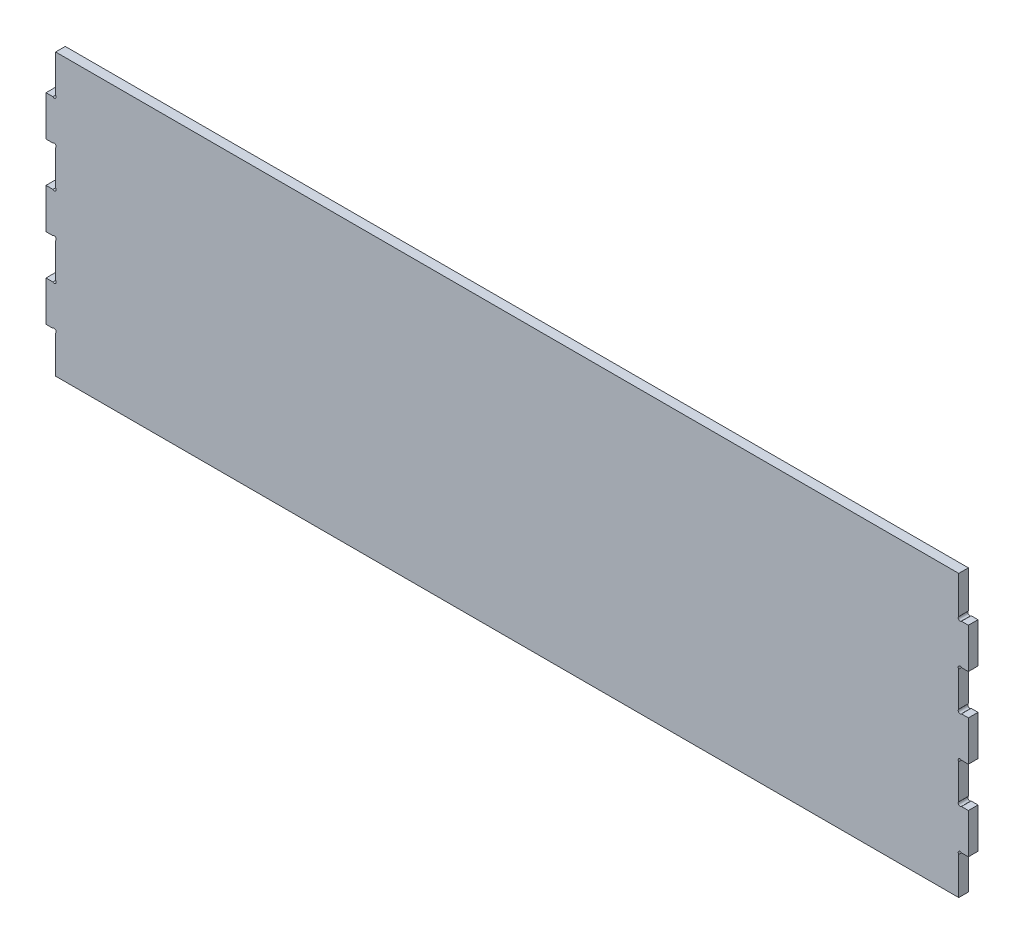
from build123d import *

# Parameters (mm, degrees)
BOSS_EXTRUDE1_DEPTH = 12


with BuildPart() as part:
    # Sketch1 → Boss-Extrude1 (new body)
    with BuildSketch(Plane.XY):
        with BuildLine():
            Line((511.8067094, 188.903885219), (511.8067094, 142.299329353))
            ThreePointArc((511.8067094, 142.299329353), (511.806507744, 138.903885219), (515.20195099, 138.906348311))
            Line((515.20195099, 138.906348311), (523.8067094, 138.906348311))
            Line((523.8067094, 138.906348311), (523.8067094, 138.319810176))
            Line((523.8067094, 138.319810176), (523.8067094, 88.903885219))
            Line((523.8067094, 88.903885219), (518.8067094, 88.903885219))
            Line((518.8067094, 88.903885219), (515.20195099, 88.903885219))
            ThreePointArc((515.20195099, 88.903885219), (511.806507744, 88.906348311), (511.8067094, 85.510904177))
            Line((511.8067094, 85.510904177), (511.8067094, 42.296866261))
            ThreePointArc((511.8067094, 42.296866261), (511.806507744, 38.901422127), (515.20195099, 38.903885219))
            Line((515.20195099, 38.903885219), (518.8067094, 38.903885219))
            Line((518.8067094, 38.903885219), (523.8067094, 38.903885219))
            Line((523.8067094, 38.903885219), (523.8067094, -11.096114781))
            Line((523.8067094, -11.096114781), (518.8067094, -11.096114781))
            Line((518.8067094, -11.096114781), (515.20195099, -11.096114781))
            ThreePointArc((515.20195099, -11.096114781), (511.806507744, -11.093651689), (511.8067094, -14.489095823))
            Line((511.8067094, -14.489095823), (511.8067094, -57.703133739))
            ThreePointArc((511.8067094, -57.703133739), (511.806507744, -61.098577873), (515.20195099, -61.096114781))
            Line((515.20195099, -61.096114781), (518.8067094, -61.096114781))
            Line((518.8067094, -61.096114781), (523.8067094, -61.096114781))
            Line((523.8067094, -61.096114781), (523.8067094, -111.096114781))
            Line((523.8067094, -111.096114781), (518.8067094, -111.096114781))
            Line((518.8067094, -111.096114781), (515.20195099, -111.096114781))
            ThreePointArc((515.20195099, -111.096114781), (511.806507744, -111.093651689), (511.8067094, -114.489095823))
            Line((511.8067094, -114.489095823), (511.8067094, -161.096114781))
            Line((511.8067094, -161.096114781), (-613.922135209, -161.096114781))
            Line((-613.922135209, -161.096114781), (-613.922135209, -114.489095823))
            ThreePointArc((-613.922135209, -114.489095823), (-613.921933554, -111.093651689), (-617.3173768, -111.096114781))
            Line((-617.3173768, -111.096114781), (-620.922135209, -111.096114781))
            Line((-620.922135209, -111.096114781), (-625.922135209, -111.096114781))
            Line((-625.922135209, -111.096114781), (-625.922135209, -61.096114781))
            Line((-625.922135209, -61.096114781), (-620.922135209, -61.096114781))
            Line((-620.922135209, -61.096114781), (-617.3173768, -61.096114781))
            ThreePointArc((-617.3173768, -61.096114781), (-613.921933554, -61.098577873), (-613.922135209, -57.703133739))
            Line((-613.922135209, -57.703133739), (-613.922135209, -14.489095823))
            ThreePointArc((-613.922135209, -14.489095823), (-613.921933554, -11.093651689), (-617.3173768, -11.096114781))
            Line((-617.3173768, -11.096114781), (-620.922135209, -11.096114781))
            Line((-620.922135209, -11.096114781), (-625.922135209, -11.096114781))
            Line((-625.922135209, -11.096114781), (-625.922135209, 38.903885219))
            Line((-625.922135209, 38.903885219), (-620.922135209, 38.903885219))
            Line((-620.922135209, 38.903885219), (-617.3173768, 38.903885219))
            ThreePointArc((-617.3173768, 38.903885219), (-613.921933554, 38.901422127), (-613.922135209, 42.296866261))
            Line((-613.922135209, 42.296866261), (-613.922135209, 85.510904177))
            ThreePointArc((-613.922135209, 85.510904177), (-613.921933554, 88.906348311), (-617.3173768, 88.903885219))
            Line((-617.3173768, 88.903885219), (-620.922135209, 88.903885219))
            Line((-620.922135209, 88.903885219), (-625.922135209, 88.903885219))
            Line((-625.922135209, 88.903885219), (-625.922135209, 138.319810176))
            Line((-625.922135209, 138.319810176), (-625.922135209, 138.906348311))
            Line((-625.922135209, 138.906348311), (-617.3173768, 138.906348311))
            ThreePointArc((-617.3173768, 138.906348311), (-613.921933554, 138.903885219), (-613.922135209, 142.299329353))
            Line((-613.922135209, 142.299329353), (-613.922135209, 188.903885219))
            Line((-613.922135209, 188.903885219), (511.8067094, 188.903885219))
        make_face()
    extrude(amount=BOSS_EXTRUDE1_DEPTH)


solid = part.part
